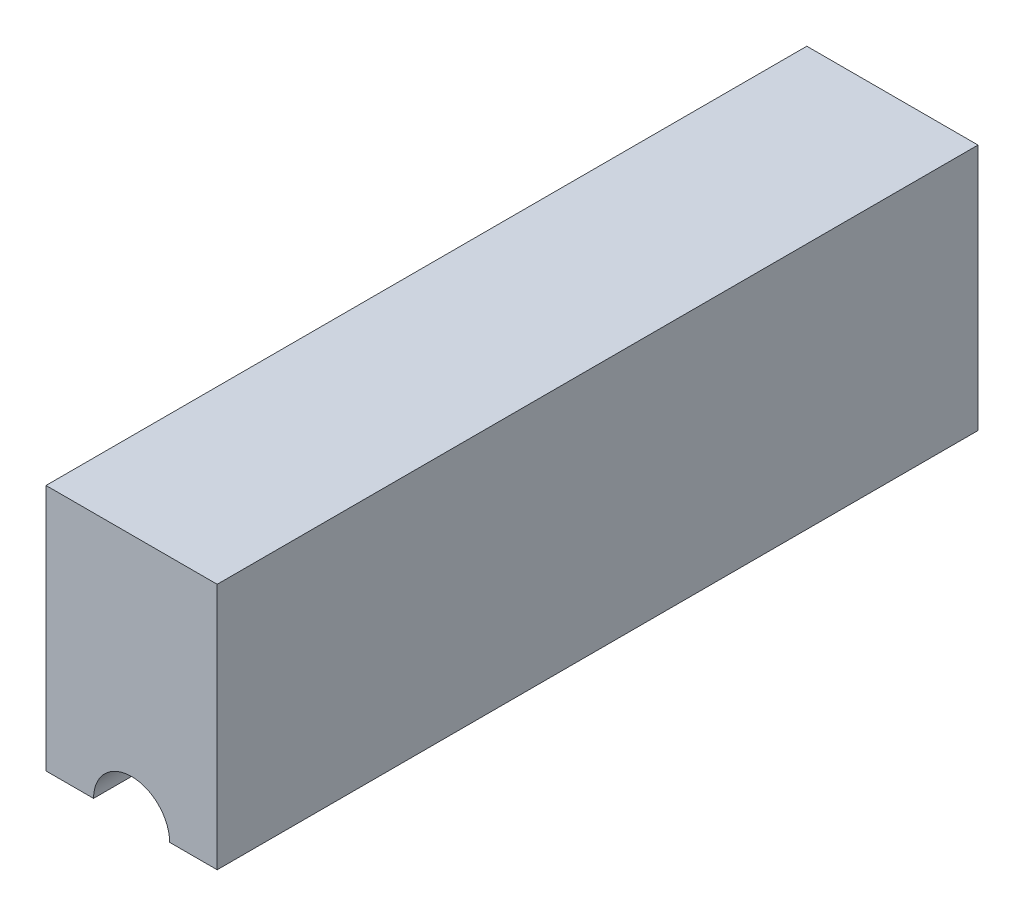
from build123d import *

# Parameters (mm, degrees)
BASE_EXTRUDE_DEPTH = 100


with BuildPart() as part:
    # Sketch1 → Base-Extrude (new body, symmetric)
    with BuildSketch(Plane.XY):
        with BuildLine():
            Line((32.5, 0), (45, 0))
            Line((45, 0), (45, 65))
            Line((45, 65), (0, 65))
            Line((0, 65), (0, 0))
            Line((0, 0), (12.5, 0))
            ThreePointArc((12.5, 0), (22.5, 10), (32.5, 0))
        make_face()
    extrude(amount=BASE_EXTRUDE_DEPTH, both=True)


solid = part.part
